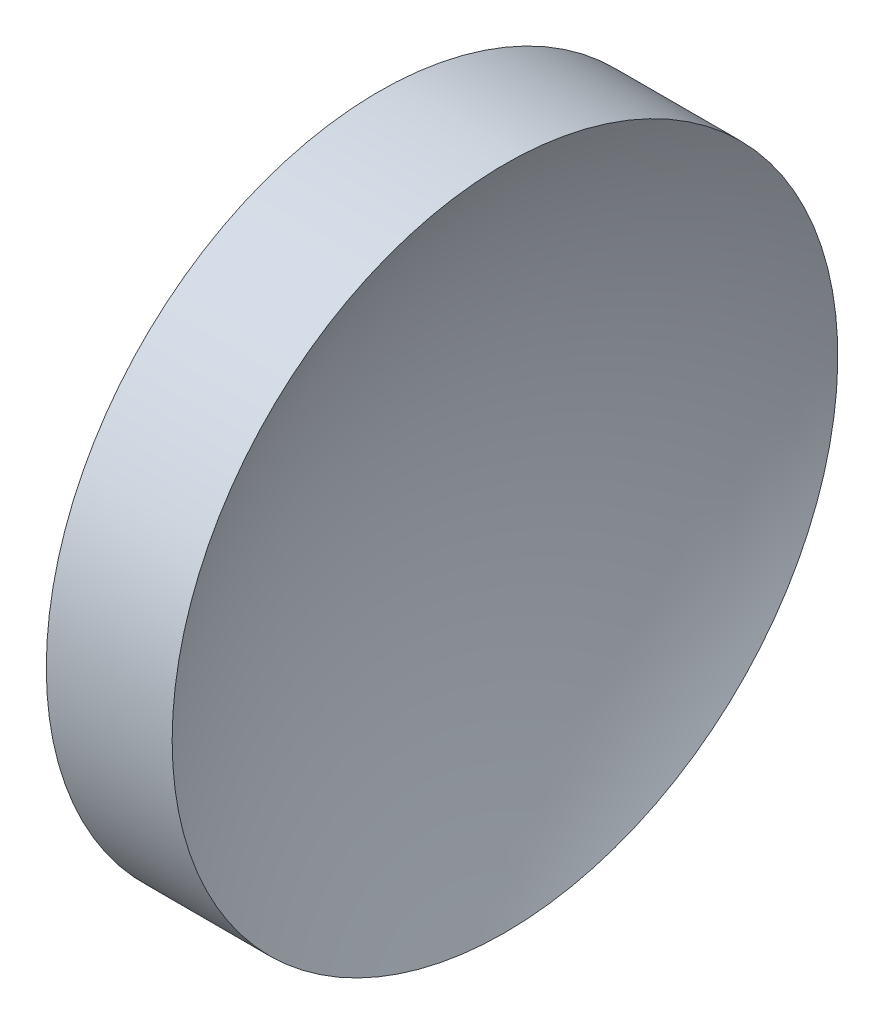
from build123d import *


with BuildPart() as part:
    # 草图1 → 旋转1 (revolve)
    with BuildSketch(Plane.XY, mode=Mode.PRIVATE) as revolve_1_sk:
        with BuildLine():
            Line((113.739437135, 65.155630457), (113.739437135, 90.155630457))
            Line((113.739437135, 90.155630457), (123.194377657, 90.155630457))
            ThreePointArc((123.194377657, 90.155630457), (118.379206778, 78.065570979), (116.739437135, 65.155630457))
            Line((116.739437135, 65.155630457), (113.739437135, 65.155630457))
        make_face()
    revolve(revolve_1_sk.sketch.rotate(Axis((105.621837124, 65.155630457, 0), (1, 0, 0)), 180), axis=Axis((105.621837124, 65.155630457, 0), (1, 0, 0)))  # turned: the seam where the file's is


solid = part.part
